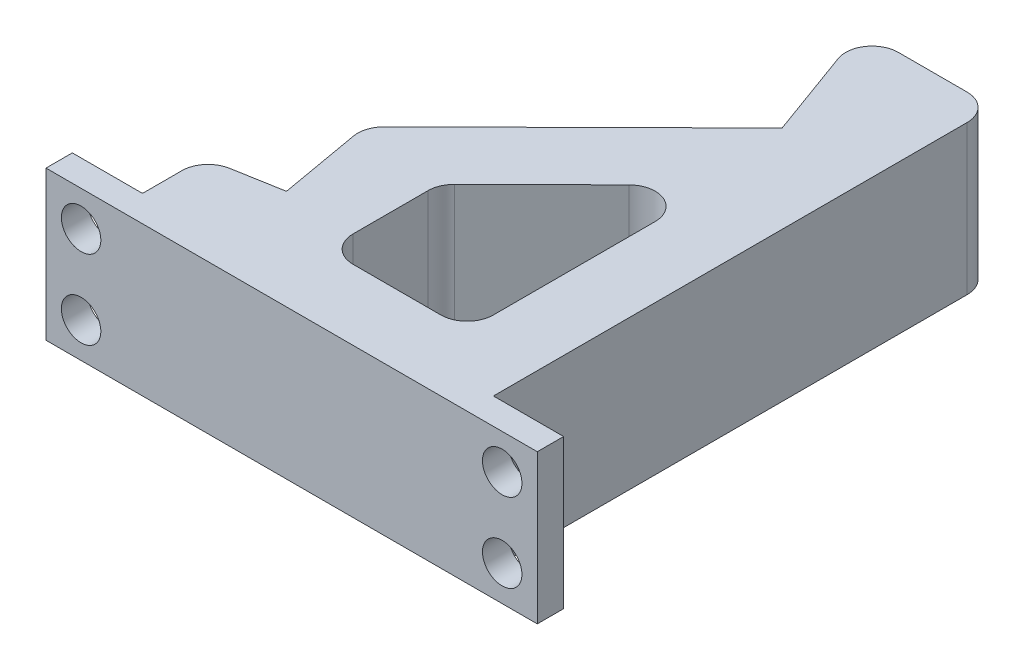
from build123d import *

# Parameters (mm, degrees)
BOSS_EXTRUDE1_DEPTH = 8.5
FILLET1_R           = 3
SKETCH2_W           = 8
SKETCH2_H           = 3
BOSS_EXTRUDE2_DEPTH = 17
SKETCH3_R           = 2.25
CUT_EXTRUDE1_DEPTH  = 4


with BuildPart() as part:
    # Sketch1 → Boss-Extrude1 (new body, symmetric)
    with BuildSketch(Plane(origin=(0, 0, 0), x_dir=(1, 0, 0), z_dir=(0, 1, 0))):
        Polygon((0, 0), (0, 10), (8, 11.410615846), (6.089870046, 22.243501129), (30, 45.904610688), (24.86969785, 60), (40, 60), (40, 0), align=None)
        Polygon((16, 8), (32, 8), (32, 36.628833574), (16, 20.795471159), align=None, mode=Mode.SUBTRACT)
    extrude(amount=BOSS_EXTRUDE1_DEPTH, both=True)

    # Fillet1
    fillet1_edges = [part.edges().sort_by_distance(p)[0] for p in [
        (0, 0, -10),
        (6.089870046, 0, -22.243501129),
        (24.86969785, 0, -60),
        (40, 0, -60),
        (16, 0, -20.795471159),
        (16, 0, -8),
        (32, 0, -8),
        (32, 0, -36.628833574),
    ]]
    fillet(fillet1_edges, radius=FILLET1_R)

    # Sketch2 → Boss-Extrude2 (add)
    with BuildSketch(Plane(origin=(0, 8.5, 0), x_dir=(1, 0, 0), z_dir=(0, 1, 0))):
        with Locations((-4, 1.5)):
            Rectangle(SKETCH2_W, SKETCH2_H)
        with Locations((44, 1.5)):
            Rectangle(SKETCH2_W, SKETCH2_H)
    extrude(amount=-BOSS_EXTRUDE2_DEPTH)

    # Sketch3 → Cut-Extrude1 (cut, through all)
    with BuildSketch(Plane(origin=(0, 0, -3), x_dir=(-1, 0, 0), z_dir=(0, 0, -1))):
        with Locations((4, -4.5)):
            Circle(SKETCH3_R)
        with Locations((4, 4.5)):
            Circle(SKETCH3_R)
        with Locations((-44, 4.5)):
            Circle(SKETCH3_R)
        with Locations((-44, -4.5)):
            Circle(SKETCH3_R)
    extrude(amount=-CUT_EXTRUDE1_DEPTH, mode=Mode.SUBTRACT)


solid = part.part
